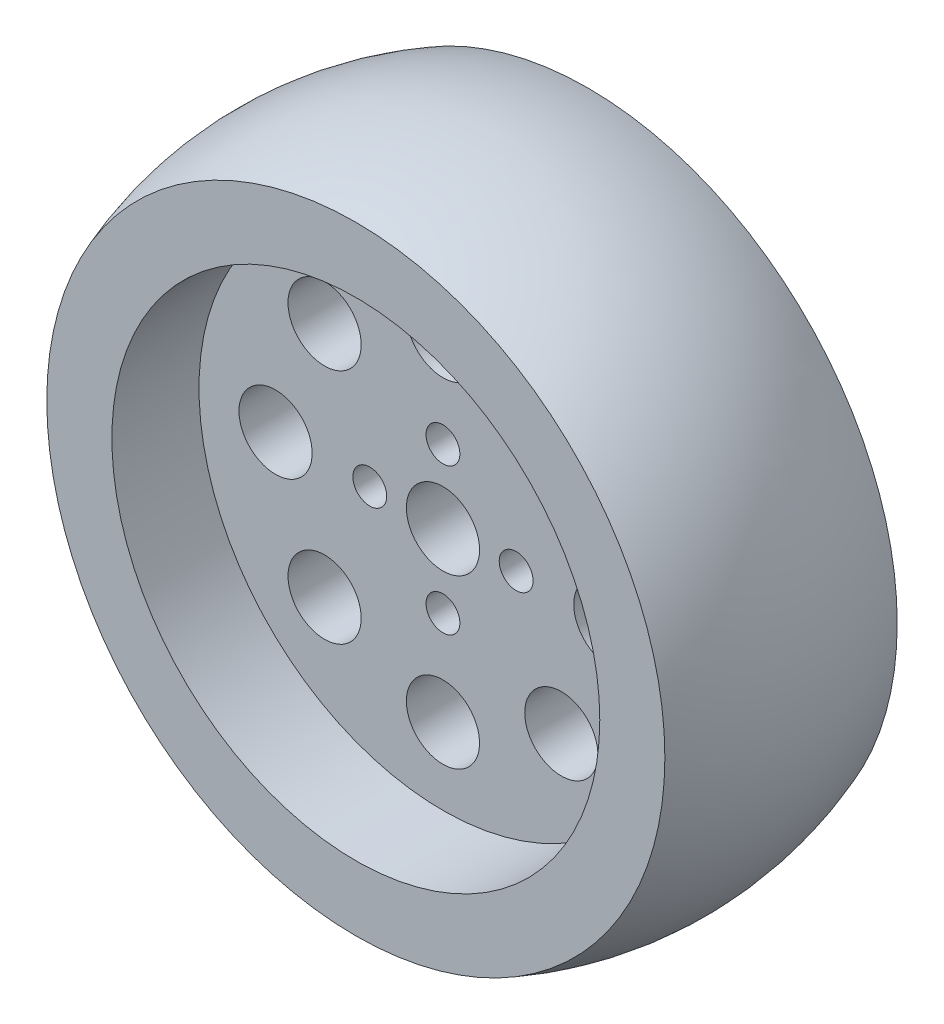
from build123d import *

# Parameters (mm, degrees)
F_8_0_8_DIAMETER_HOLE1_D       = 8
F_8_0_8_DIAMETER_HOLE1_DEPTH   = 15.875
F_3_7_3_7_DIAMETER_HOLE1_D     = 3.7
F_3_7_3_7_DIAMETER_HOLE1_DEPTH = 15.875


with BuildPart() as part:
    # Sketch1 → Revolve1 (revolve)
    with BuildSketch(Plane(origin=(0, 0, 0), x_dir=(1, 0, 0), z_dir=(0, 1, 0))):
        with BuildLine():
            Line((33.785456803, 12.7), (0, 12.7))
            Line((0, 12.7), (0, -12.7))
            Line((0, -12.7), (33.785456803, -12.7))
            ThreePointArc((33.785456803, -12.7), (36.1, 0), (33.785456803, 12.7))
        make_face()
    revolve(axis=Axis((0, 0, -12.7), (0, 0, 1)))

    # Sketch2 → Cut-Revolve1 (revolve, cut)
    with BuildSketch(Plane(origin=(0, 0, 0), x_dir=(1, 0, 0), z_dir=(0, 1, 0))):
        Polygon((26.67, 12.7), (0, 12.7), (0, -12.7), (26.67, -12.7), (26.67, -3.175), (4, -3.175), (4, 3.175), (26.67, 3.175), align=None)
    revolve(axis=Axis((0, 0, -12.7), (0, 0, 1)), mode=Mode.SUBTRACT)

    # Ø8.0 (8) Diameter Hole1
    with Locations(Plane(origin=(0, 0, -3.175), x_dir=(-1, 0, 0), z_dir=(0, 0, -1))):
        with Locations((0, -18.3), (-12.940054096, -12.940054096), (-18.3, 0), (-12.940054096, 12.940054096), (0, 18.3), (12.940054096, 12.940054096), (18.3, 0), (12.940054096, -12.940054096)):
            Hole(F_8_0_8_DIAMETER_HOLE1_D / 2, depth=F_8_0_8_DIAMETER_HOLE1_DEPTH)

    # Ø3.7 (3.7) Diameter Hole1
    with Locations(Plane(origin=(0, 0, -3.175), x_dir=(-1, 0, 0), z_dir=(0, 0, -1))):
        with Locations((-8, 0), (0, -8), (8, 0), (0, 8)):
            Hole(F_3_7_3_7_DIAMETER_HOLE1_D / 2, depth=F_3_7_3_7_DIAMETER_HOLE1_DEPTH)


solid = part.part
